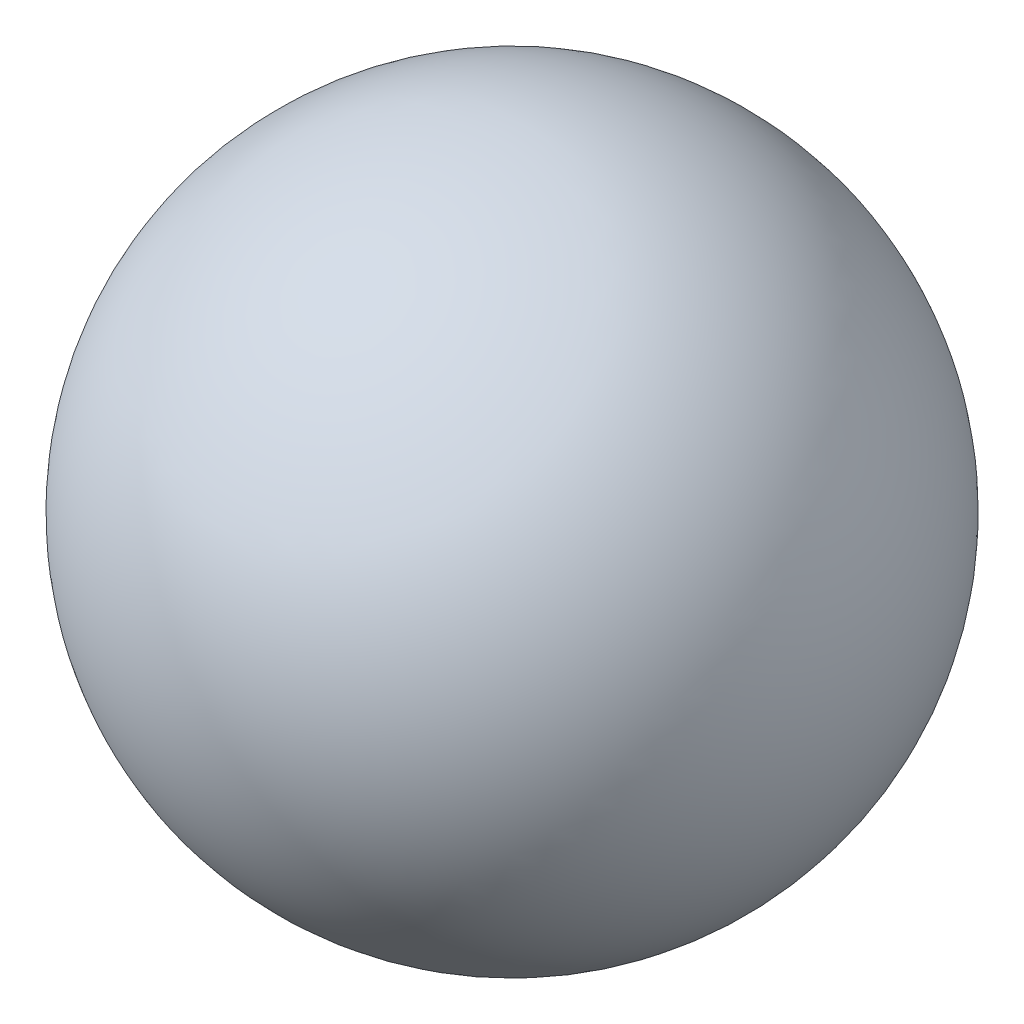
from build123d import *


with BuildPart() as part:
    # Sketch1 → Revolve1 (revolve)
    with BuildSketch(Plane(origin=(0, 0, 0), x_dir=(1, 0, 0), z_dir=(0, 1, 0))):
        with BuildLine():
            Line((0, 0), (0, 500))
            ThreePointArc((0, 500), (250, 250), (0, 0))
        make_face()
    revolve(axis=Axis((0, 0, 0), (0, 0, -1)))


solid = part.part
